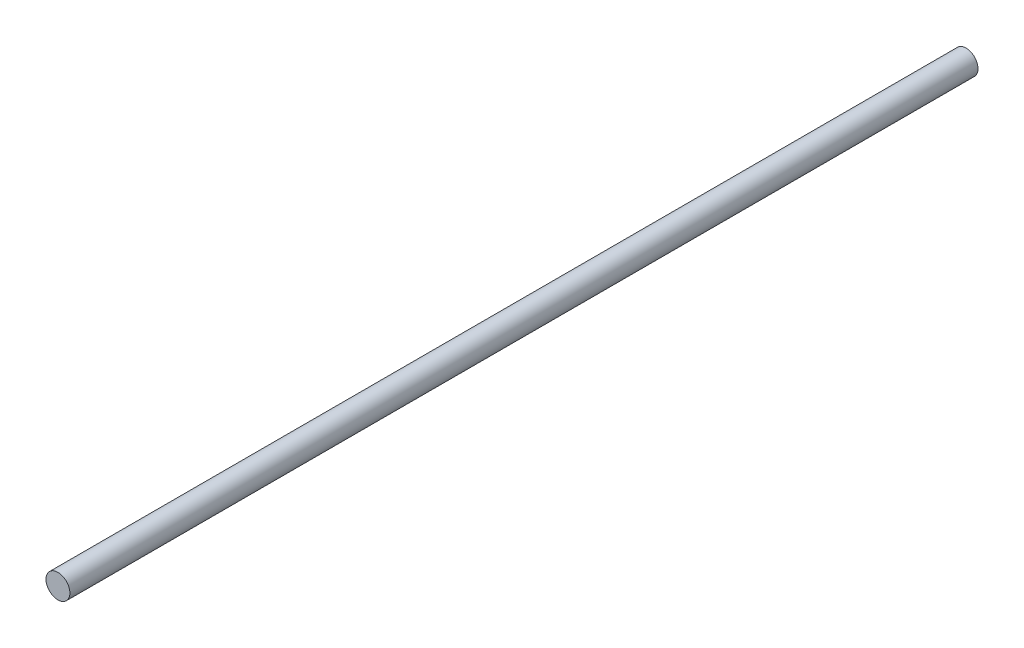
from build123d import *

# Parameters (mm, degrees)
SKETCH1_R           = 5
BOSS_EXTRUDE1_DEPTH = 380


with BuildPart() as part:
    # Sketch1 → Boss-Extrude1 (new body)
    with BuildSketch(Plane.XY):
        Circle(SKETCH1_R)
    extrude(amount=BOSS_EXTRUDE1_DEPTH)


solid = part.part
